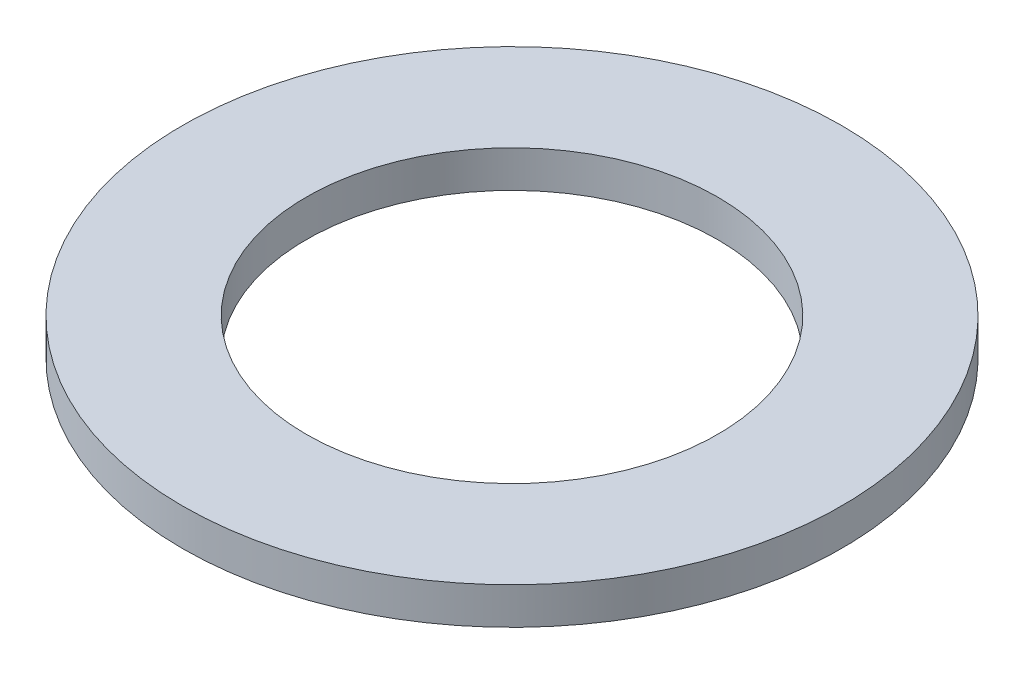
from build123d import *

# Parameters (mm, degrees)
SKETCH1_R           = 7.9375
BOSS_EXTRUDE1_DEPTH = 0.889
SKETCH5_R           = 4.953
CUT_EXTRUDE1_DEPTH  = 1.889


with BuildPart() as part:
    # Sketch1 → Boss-Extrude1 (new body)
    with BuildSketch(Plane(origin=(0, 0, 0), x_dir=(1, 0, 0), z_dir=(0, 1, 0))):
        Circle(SKETCH1_R)
    extrude(amount=BOSS_EXTRUDE1_DEPTH)

    # Sketch5 → Cut-Extrude1 (cut, through all)
    with BuildSketch(Plane(origin=(0, 0.889, 0), x_dir=(-1, 0, 0), z_dir=(0, 1, 0))):
        Circle(SKETCH5_R)
    extrude(amount=-CUT_EXTRUDE1_DEPTH, mode=Mode.SUBTRACT)


solid = part.part
